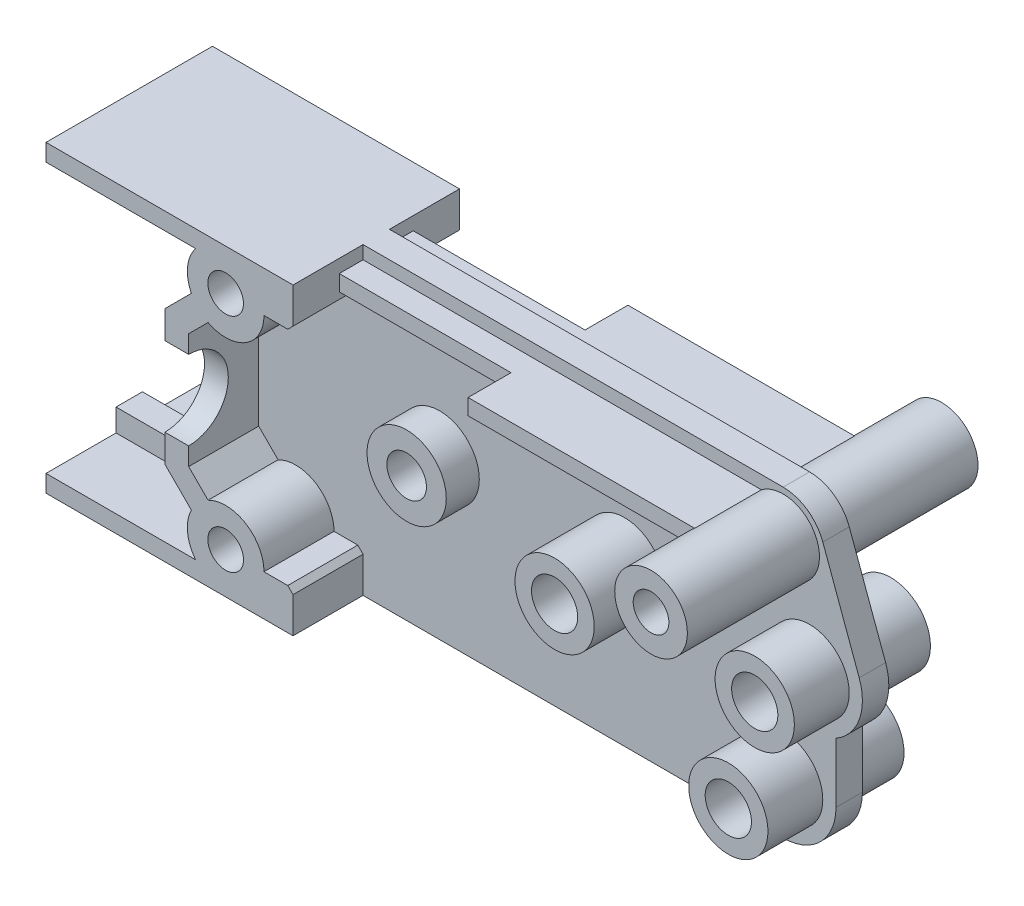
from build123d import *

# Parameters (mm, degrees)
SKETCH2_R           = 1.35
SKETCH2_R_2         = 1.5
SKETCH2_R_3         = 1.75
BOSS_EXTRUDE1_DEPTH = 1
SKETCH3_R           = 3
SKETCH3_R_2         = 1.75
BOSS_EXTRUDE2_DEPTH = 5.15
SKETCH4_R           = 3
SKETCH4_R_2         = 1.75
BOSS_EXTRUDE3_DEPTH = 6.3
SKETCH5_R           = 3
SKETCH5_R_2         = 1.5
BOSS_EXTRUDE4_DEPTH = 3.5
SKETCH6_R           = 2.75
SKETCH6_R_2         = 1.35
BOSS_EXTRUDE5_DEPTH = 11
SKETCH7_R           = 1.35
BOSS_EXTRUDE6_DEPTH = 6.3
BOSS_EXTRUDE7_DEPTH = 1.2
SKETCH9_R           = 1.35
CUT_EXTRUDE1_DEPTH  = 23
CUT_EXTRUDE2_REACH  = 49.5
CHAMFER2_SIZE       = 0.4


with BuildPart() as part:
    # Sketch2 → Boss-Extrude1 (new body, symmetric)
    with BuildSketch(Plane.XY):
        with BuildLine():
            Line((0, 0), (50.5, 0))
            ThreePointArc((50.5, 0), (53.328427125, 1.171572875), (54.5, 4))
            Line((54.5, 4), (54.5, 8.535898385))
            ThreePointArc((54.5, 8.535898385), (56.259762135, 10.634647047), (56.256781243, 13.373533652))
            Line((56.256781243, 13.373533652), (53.505424994, 20.898826922))
            ThreePointArc((53.505424994, 20.898826922), (52.33354218, 22.4226176), (50.5, 23))
            Line((50.5, 23), (0, 23))
            Line((0, 23), (0, 20))
            Line((0, 20), (9, 20))
            Line((9, 20), (9, 3))
            Line((9, 3), (0, 3))
            Line((0, 3), (0, 0))
        make_face()
        with Locations((13.6, 3.1)):
            Circle(SKETCH2_R, mode=Mode.SUBTRACT)
        with Locations((24.5, 12)):
            Circle(SKETCH2_R_2, mode=Mode.SUBTRACT)
        with Locations((38.5, 12)):
            Circle(SKETCH2_R_3, mode=Mode.SUBTRACT)
        with Locations((52.5, 12)):
            Circle(SKETCH2_R_3, mode=Mode.SUBTRACT)
        with Locations((50.5, 4)):
            Circle(SKETCH2_R_3, mode=Mode.SUBTRACT)
        with Locations((50.5, 19.8)):
            Circle(SKETCH2_R, mode=Mode.SUBTRACT)
        with Locations((13.6, 19.9)):
            Circle(SKETCH2_R, mode=Mode.SUBTRACT)
    extrude(amount=BOSS_EXTRUDE1_DEPTH, both=True)

    # Sketch3 → Boss-Extrude2 (add, symmetric)
    with BuildSketch(Plane.XY):
        with Locations((50.5, 4)):
            Circle(SKETCH3_R)
        with Locations((50.5, 4)):
            Circle(SKETCH3_R_2, mode=Mode.SUBTRACT)
        with Locations((52.5, 12)):
            Circle(SKETCH3_R)
        with Locations((52.5, 12)):
            Circle(SKETCH3_R_2, mode=Mode.SUBTRACT)
    extrude(amount=BOSS_EXTRUDE2_DEPTH, both=True)

    # Sketch4 → Boss-Extrude3 (add, symmetric)
    with BuildSketch(Plane.XY):
        with Locations((38.5, 12)):
            Circle(SKETCH4_R)
        with Locations((38.5, 12)):
            Circle(SKETCH4_R_2, mode=Mode.SUBTRACT)
    extrude(amount=BOSS_EXTRUDE3_DEPTH, both=True)

    # Sketch5 → Boss-Extrude4 (add, symmetric)
    with BuildSketch(Plane.XY):
        with Locations((24.5, 12)):
            Circle(SKETCH5_R)
        with Locations((24.5, 12)):
            Circle(SKETCH5_R_2, mode=Mode.SUBTRACT)
    extrude(amount=BOSS_EXTRUDE4_DEPTH, both=True)

    # Sketch6 → Boss-Extrude5 (add, symmetric)
    with BuildSketch(Plane.XY):
        with Locations((50.5, 19.8)):
            Circle(SKETCH6_R)
        with Locations((50.5, 19.8)):
            Circle(SKETCH6_R_2, mode=Mode.SUBTRACT)
    extrude(amount=BOSS_EXTRUDE5_DEPTH, both=True)

    # Sketch7 → Boss-Extrude6 (add, symmetric)
    with BuildSketch(Plane.XY):
        with BuildLine():
            Line((0, 23), (18.7, 23))
            Line((18.7, 23), (18.7, 19.9))
            Line((18.7, 19.9), (16.5, 19.9))
            ThreePointArc((16.5, 19.9), (15.108348306, 17.423129921), (12.269044559, 17.323460147))
            Line((12.269044559, 17.323460147), (10.8, 15.854415588))
            Line((10.8, 15.854415588), (10.8, 11.5))
            Line((10.8, 11.5), (10.8, 7.145584412))
            Line((10.8, 7.145584412), (12.269044559, 5.676539853))
            ThreePointArc((12.269044559, 5.676539853), (15.108348306, 5.576870079), (16.5, 3.1))
            Line((16.5, 3.1), (18.7, 3.1))
            Line((18.7, 3.1), (18.7, 0))
            Line((18.7, 0), (0, 0))
            Line((0, 0), (0, 1.3))
            Line((0, 1.3), (11.3262366, 1.3))
            ThreePointArc((11.3262366, 1.3), (10.715483905, 2.800722707), (11.005134966, 4.394865034))
            Line((11.005134966, 4.394865034), (9, 6.4))
            Line((9, 6.4), (9, 11.5))
            Line((9, 11.5), (9, 16.6))
            Line((9, 16.6), (11.005134966, 18.605134966))
            ThreePointArc((11.005134966, 18.605134966), (10.715483905, 20.199277293), (11.3262366, 21.7))
            Line((11.3262366, 21.7), (0, 21.7))
            Line((0, 21.7), (0, 23))
        make_face()
        with Locations((13.6, 3.1)):
            Circle(SKETCH7_R, mode=Mode.SUBTRACT)
        with Locations((13.6, 19.9)):
            Circle(SKETCH7_R, mode=Mode.SUBTRACT)
    extrude(amount=BOSS_EXTRUDE6_DEPTH, both=True)

    # Sketch8 → Boss-Extrude7 (add)
    with BuildSketch(Plane(origin=(0, 22, 0), x_dir=(-1, 0, 0), z_dir=(0, 1, 0))):
        Polygon((-18.7, -2.8), (-18.7, 2.8), (-31.7, 2.8), (-31.7, 6.05), (-50.5, 6.05), (-50.5, -6.05), (-31.7, -6.05), (-31.7, -2.8), align=None)
    extrude(amount=-BOSS_EXTRUDE7_DEPTH)

    # Sketch9 → Cut-Extrude1 (cut, through all)
    with BuildSketch(Plane(origin=(0, 0, -11), x_dir=(-1, 0, 0), z_dir=(0, 0, -1))):
        with Locations((-50.5, 19.8)):
            Circle(SKETCH9_R)
    extrude(amount=-CUT_EXTRUDE1_DEPTH, mode=Mode.SUBTRACT)

    # Sketch10 → Cut-Extrude2 (cut, up to next)
    with BuildSketch(Plane.ZY.offset(-9), mode=Mode.PRIVATE) as cut_extrude2_sk1:
        with BuildLine():
            Line((-6.3, 14.5), (-6.3, 8.5))
            ThreePointArc((-6.3, 8.5), (-3.3, 11.5), (-6.3, 14.5))
        make_face()
    cut_extrude2_tool1 = extrude(cut_extrude2_sk1.sketch, amount=-CUT_EXTRUDE2_REACH, mode=Mode.PRIVATE) & part.part
    add(cut_extrude2_tool1.solids().sort_by_distance((9, 11.5, -5.02676))[0], mode=Mode.SUBTRACT)
    # Sketch10 → Cut-Extrude2 (cut, up to next)
    with BuildSketch(Plane.ZY.offset(-9), mode=Mode.PRIVATE) as cut_extrude2_sk2:
        with BuildLine():
            Line((6.3, 8.5), (6.3, 14.5))
            ThreePointArc((6.3, 14.5), (3.3, 11.5), (6.3, 8.5))
        make_face()
    cut_extrude2_tool2 = extrude(cut_extrude2_sk2.sketch, amount=-CUT_EXTRUDE2_REACH, mode=Mode.PRIVATE) & part.part
    add(cut_extrude2_tool2.solids().sort_by_distance((9, 11.5, 5.02676))[0], mode=Mode.SUBTRACT)

    # Chamfer2
    chamfer2_edges = [part.edges().sort_by_distance(p)[0] for p in [
        (18.7, 3.1, -3.65),
        (18.7, 19.9, -3.65),
        (18.7, 3.1, 3.65),
        (18.7, 19.9, 3.65),
    ]]
    chamfer(chamfer2_edges, length=CHAMFER2_SIZE)


solid = part.part
